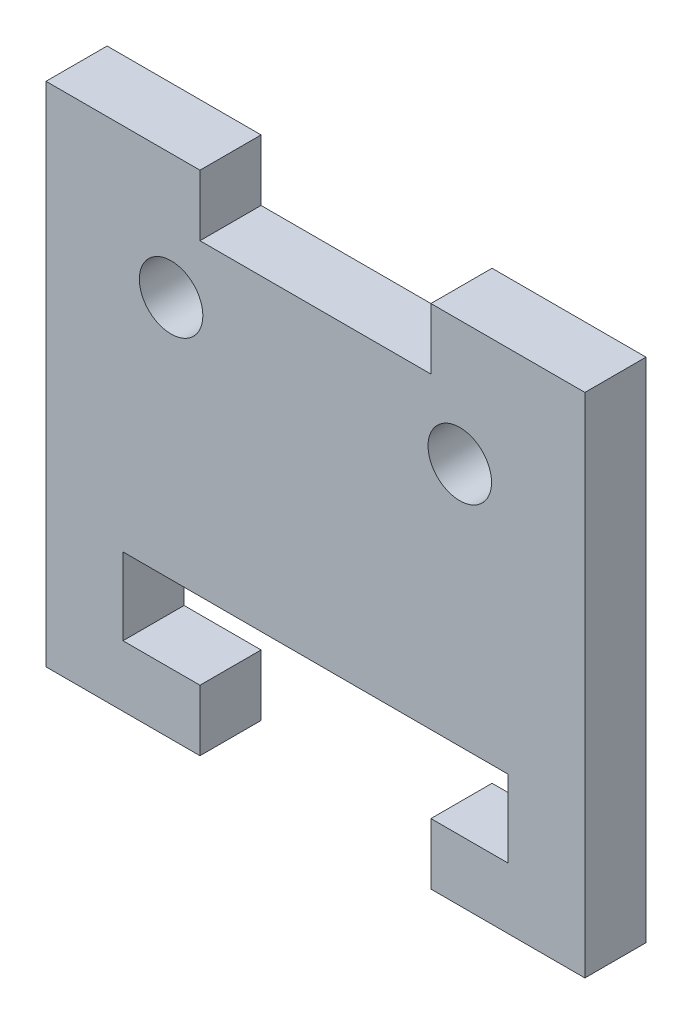
from build123d import *

# Parameters (mm, degrees)
SKETCH1_R           = 1.65
BOSS_EXTRUDE1_DEPTH = 3.175


with BuildPart() as part:
    # Sketch1 → Boss-Extrude1 (new body)
    with BuildSketch(Plane.XY):
        Polygon((-14, 13.175), (-14, 10), (-14, -10), (-14, -13.175), (-6, -13.175), (-6, -10), (-10, -10), (-10, -6), (10, -6), (10, -10), (6, -10), (6, -13.175), (14, -13.175), (14, -10), (14, 10), (14, 13.175), (6, 13.175), (6, 10), (-6, 10), (-6, 13.175), align=None)
        with Locations((-7.5, 6.7)):
            Circle(SKETCH1_R, mode=Mode.SUBTRACT)
        with Locations((7.5, 6.7)):
            Circle(SKETCH1_R, mode=Mode.SUBTRACT)
    extrude(amount=BOSS_EXTRUDE1_DEPTH)


solid = part.part
